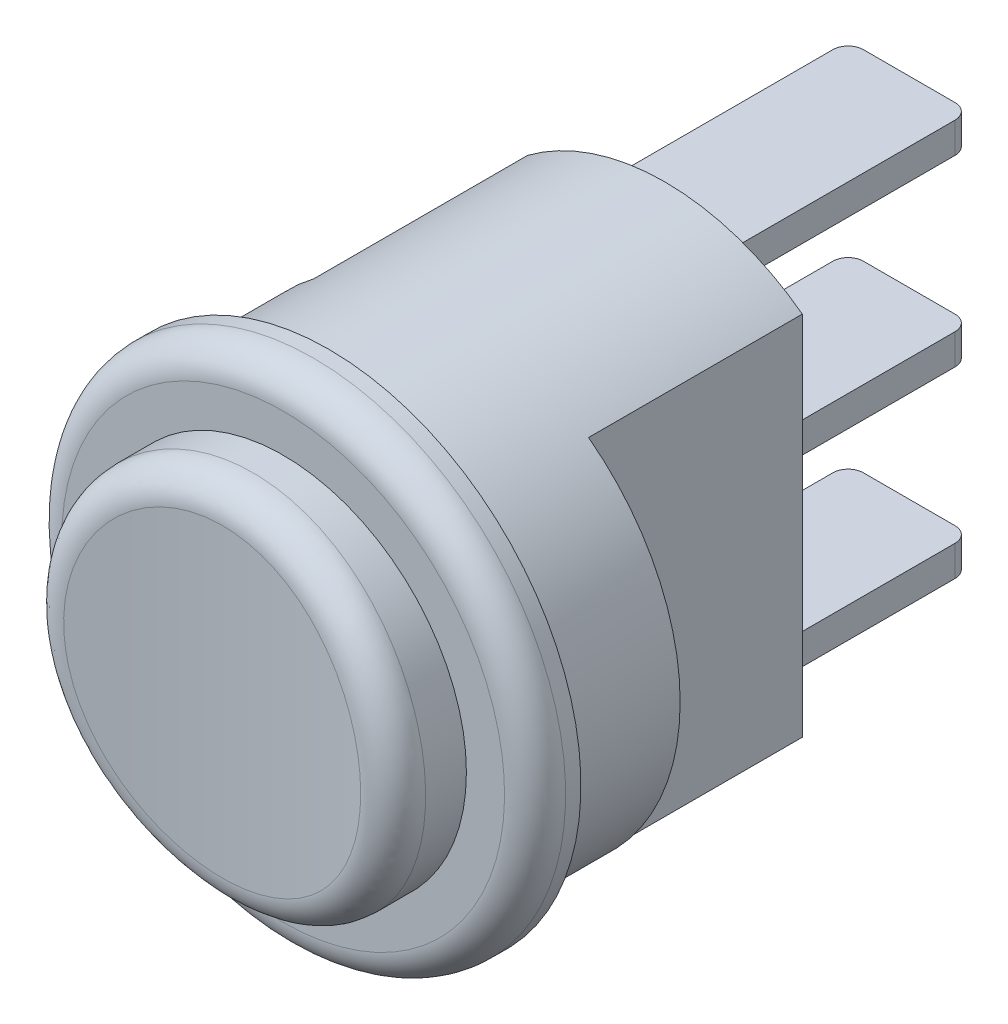
from build123d import *

# Parameters (mm, degrees)
CUT_EXTRUDE_1_DEPTH = 7
SKETCH_3_R          = 6
EXTRUDE_1_DEPTH     = 2.5
CUT_EXTRUDE_2_DEPTH = 7.5
FILLET_1_R          = 1
FILLET_2_R          = 1
SKETCH_5_W          = 4
SKETCH_5_H          = 1
EXTRUDE_2_DEPTH     = 8
EXTRUDE_2_2_DEPTH   = 8
EXTRUDE_2_3_DEPTH   = 8
FILLET_3_R          = 0.5
FILLET_4_R          = 0.5
FILLET_5_R          = 0.5


with BuildPart() as part:
    # Эскиз1 → Повернуть1 (revolve)
    with BuildSketch(Plane(origin=(0, 0, 0), x_dir=(0, 0, -1), z_dir=(1, 0, 0))):
        Polygon((0, 0), (0, 8.25), (1.5, 8.25), (1.5, 7.5), (12.5, 7.5), (12.5, 0), align=None)
    revolve(axis=Axis((0, 0, -12.5), (0, 0, 1)))

    # Эскиз2 → Вырез-Вытянуть1 (cut)
    with BuildSketch(Plane(origin=(0, 0, -12.5), x_dir=(-1, 0, 0), z_dir=(0, 0, -1))):
        with BuildLine():
            Line((-4.5, -6), (-4.5, 6))
            ThreePointArc((-4.5, 6), (-7.5, 0), (-4.5, -6))
        make_face()
        with BuildLine():
            Line((4.5, -6), (4.5, 6))
            ThreePointArc((4.5, 6), (7.5, 0), (4.5, -6))
        make_face()
    extrude(amount=-CUT_EXTRUDE_1_DEPTH, mode=Mode.SUBTRACT)

    # Скругление2
    fillet_2_edges = [part.edges().sort_by_distance(p)[0] for p in [
        (0, -8.25, 0),
    ]]
    fillet(fillet_2_edges, radius=FILLET_2_R)


with BuildPart() as body_2:
    # Эскиз3 → Бобышка-Вытянуть1 (new body)
    with BuildSketch(Plane.XY):
        Circle(SKETCH_3_R)
    extrude(amount=EXTRUDE_1_DEPTH)

    # Эскиз4 → Вырез-Вытянуть2 (cut, symmetric)
    with BuildSketch(Plane(origin=(0, 0, 0), x_dir=(1, 0, 0), z_dir=(0, 1, 0))):
        with BuildLine():
            Line((-6, -2.5), (6, -2.5))
            ThreePointArc((6, -2.5), (0, -1.991065566), (-6, -2.5))
        make_face()
    extrude(amount=CUT_EXTRUDE_2_DEPTH, both=True, mode=Mode.SUBTRACT)

    # Скругление1
    fillet_1_edges = [body_2.edges().sort_by_distance(p)[0] for p in [
        (-6, 5.7e-07, 2.5),
    ]]
    fillet(fillet_1_edges, radius=FILLET_1_R)


with BuildPart() as body_3:
    # Эскиз5 → Бобышка-Вытянуть2 (new body)
    with BuildSketch(Plane(origin=(0, 0, -12.5), x_dir=(-1, 0, 0), z_dir=(0, 0, -1))):
        with Locations((0, 6)):
            Rectangle(SKETCH_5_W, SKETCH_5_H)
    extrude(amount=EXTRUDE_2_DEPTH)

    # Скругление5
    fillet_5_edges = [body_3.edges().sort_by_distance(p)[0] for p in [
        (-2, 6, -20.5),
        (2, 6, -20.5),
    ]]
    fillet(fillet_5_edges, radius=FILLET_5_R)


with BuildPart() as body_4:
    # Эскиз5 → Extrude 2 2 (new body)
    with BuildSketch(Plane(origin=(0, 0, -12.5), x_dir=(-1, 0, 0), z_dir=(0, 0, -1))):
        Rectangle(SKETCH_5_W, SKETCH_5_H)
    extrude(amount=EXTRUDE_2_2_DEPTH)

    # Скругление4
    fillet_4_edges = [body_4.edges().sort_by_distance(p)[0] for p in [
        (-2, 0, -20.5),
        (2, 0, -20.5),
    ]]
    fillet(fillet_4_edges, radius=FILLET_4_R)


with BuildPart() as body_5:
    # Эскиз5 → Extrude 2 3 (new body)
    with BuildSketch(Plane(origin=(0, 0, -12.5), x_dir=(-1, 0, 0), z_dir=(0, 0, -1))):
        with Locations((0, -6)):
            Rectangle(SKETCH_5_W, SKETCH_5_H)
    extrude(amount=EXTRUDE_2_3_DEPTH)

    # Скругление3
    fillet_3_edges = [body_5.edges().sort_by_distance(p)[0] for p in [
        (-2, -6, -20.5),
        (2, -6, -20.5),
    ]]
    fillet(fillet_3_edges, radius=FILLET_3_R)


solid = Compound([part.part, body_2.part, body_3.part, body_4.part, body_5.part])
